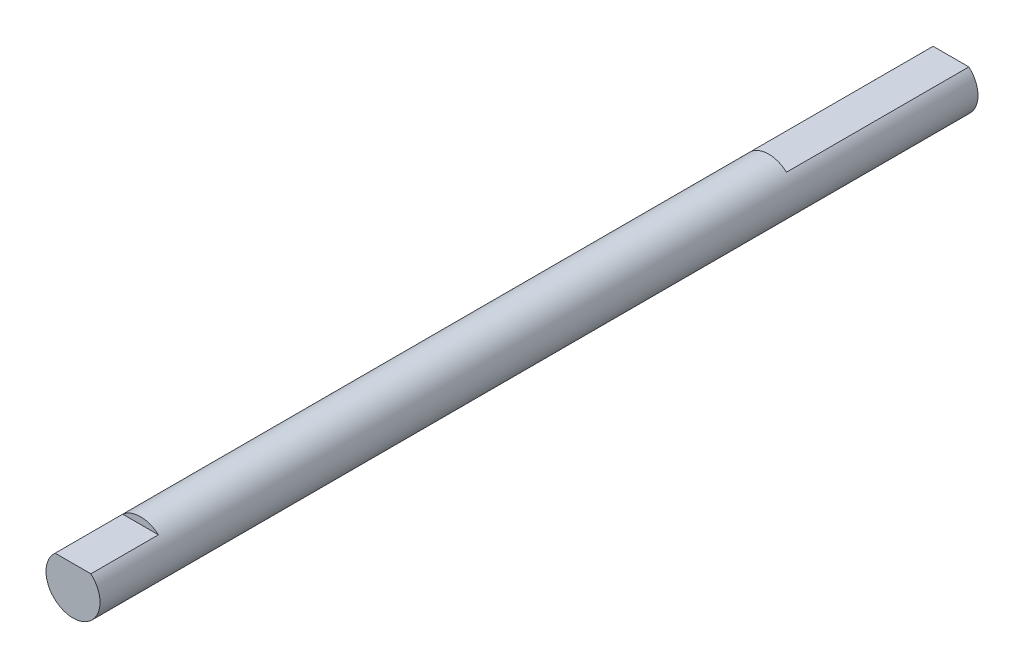
from build123d import *

# Parameters (mm, degrees)
ESBO_O1_R                     = 4
RESSALTO_EXTRUS_O1_DEPTH      = 72
RESSALTO_EXTRUS_O1_DEPTH_BACK = 58
CORTE_EXTRUS_O1_DEPTH         = 10
CORTE_EXTRUS_O2_DEPTH         = 27


with BuildPart() as part:
    # Esboço1 → Ressalto-extrusão1 (new body, two sides)
    with BuildSketch(Plane.XY) as ressalto_extrus_o1_sk:
        Circle(ESBO_O1_R)
    extrude(amount=RESSALTO_EXTRUS_O1_DEPTH)
    extrude(ressalto_extrus_o1_sk.sketch, amount=-RESSALTO_EXTRUS_O1_DEPTH_BACK)

    # Esboço2 → Corte-extrusão1 (cut)
    with BuildSketch(Plane.XY.offset(72)):
        with BuildLine():
            Line((2.645751311, 3), (-2.645751311, 3))
            ThreePointArc((-2.645751311, 3), (0, 4), (2.645751311, 3))
        make_face()
    extrude(amount=-CORTE_EXTRUS_O1_DEPTH, mode=Mode.SUBTRACT)

    # Esboço6 → Corte-extrusão2 (cut)
    with BuildSketch(Plane(origin=(0, 0, -58), x_dir=(-1, 0, 0), z_dir=(0, 0, -1))):
        with BuildLine():
            Line((2.645751311, 3), (-2.645751311, 3))
            ThreePointArc((-2.645751311, 3), (0, 4), (2.645751311, 3))
        make_face()
    extrude(amount=-CORTE_EXTRUS_O2_DEPTH, mode=Mode.SUBTRACT)


solid = part.part
